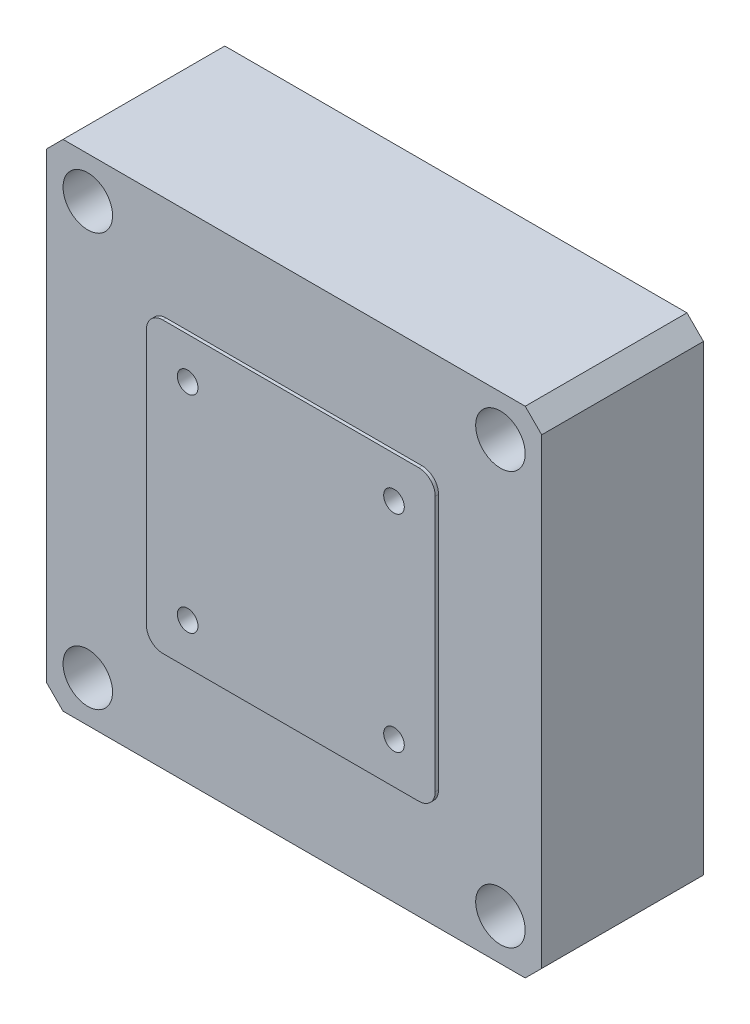
from build123d import *

# Parameters (mm, degrees)
SKETCH_1_W                = 60
SKETCH_1_H                = 60
EXTRUDE_1_DEPTH           = 19.6
CHAMFER_1_SIZE            = 2
SKETCH_2_W                = 35
SKETCH_2_H                = 35
EXTRUDE_2_DEPTH           = 0.4
FILLET_1_R                = 2
HOLE_WIZARD_1_D           = 3.4
HOLE_WIZARD_1_CBORE_D     = 6
HOLE_WIZARD_1_CBORE_DEPTH = 5
HOLE_WIZARD_M3_1_D        = 2.5
HOLE_WIZARD_M3_1_DEPTH    = 3.5
HOLE_WIZARD_M3_1_TIP      = 0.751075774


with BuildPart() as part:
    # 草图1 → 凸台-拉伸1 (new body)
    with BuildSketch(Plane.XY):
        Rectangle(SKETCH_1_W, SKETCH_1_H)
    extrude(amount=EXTRUDE_1_DEPTH)

    # 倒角1
    chamfer_1_edges = [part.edges().sort_by_distance(p)[0] for p in [
        (30, -30, 9.8),
        (-30, -30, 9.8),
        (-30, 30, 9.8),
        (30, 30, 9.8),
    ]]
    chamfer(chamfer_1_edges, length=CHAMFER_1_SIZE)

    # 草图2 → 凸台-拉伸2 (add)
    with BuildSketch(Plane.XY.offset(19.6)):
        Rectangle(SKETCH_2_W, SKETCH_2_H)
    extrude(amount=EXTRUDE_2_DEPTH)

    # 圆角1
    fillet_1_edges = [part.edges().sort_by_distance(p)[0] for p in [
        (17.5, -17.5, 19.8),
        (17.5, 17.5, 19.8),
        (-17.5, 17.5, 19.8),
        (-17.5, -17.5, 19.8),
    ]]
    fillet(fillet_1_edges, radius=FILLET_1_R)

    # 孔1 (through all)
    with Locations(Plane(origin=(-25, 25, 19.6), x_dir=(1, 0, 0), z_dir=(0, 0, 1))):
        with Locations((0, 0), (50, 0), (0, -50), (50, -50)):
            CounterBoreHole(HOLE_WIZARD_1_D / 2, HOLE_WIZARD_1_CBORE_D / 2, HOLE_WIZARD_1_CBORE_DEPTH)

    # M3 螺纹孔1
    with Locations(Plane(origin=(-12.5, 12.5, 20), x_dir=(1, 0, 0), z_dir=(0, 0, 1))):
        with Locations((0, 0), (25, 0), (25, -25), (0, -25)):
            Hole(HOLE_WIZARD_M3_1_D / 2, depth=HOLE_WIZARD_M3_1_DEPTH)
            with Locations((0, 0, -(HOLE_WIZARD_M3_1_DEPTH + HOLE_WIZARD_M3_1_TIP / 2))):  # 118° drill point
                Cone(0, HOLE_WIZARD_M3_1_D / 2, HOLE_WIZARD_M3_1_TIP, mode=Mode.SUBTRACT)


solid = part.part
